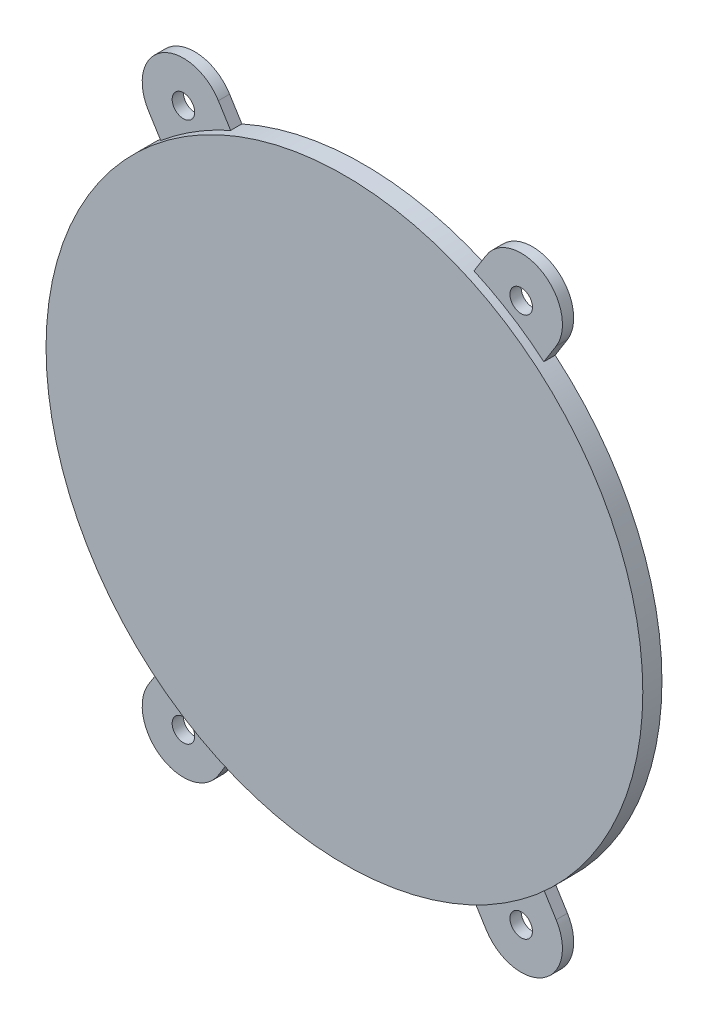
from build123d import *

# Parameters (mm, degrees)
SKETCH_1_R          = 26.5
EXTRUDE_2_DEPTH     = 1.7
EXTRUDE_3_DEPTH     = 1
SKETCH_4_R          = 1
CUT_EXTRUDE_1_DEPTH = 1


with BuildPart() as part:
    # Эскиз1 → Бобышка-Вытянуть2 (new body)
    with BuildSketch(Plane.XY):
        Circle(SKETCH_1_R)
    extrude(amount=EXTRUDE_2_DEPTH)

    # Эскиз3 → Бобышка-Вытянуть3 (add)
    with BuildSketch(Plane.XY):
        with BuildLine():
            Line((0, 6.907283337), (-11.895602995, 25.940248128))
            ThreePointArc((-11.895602995, 25.940248128), (-16.940248128, 27.104397005), (-18.104397005, 22.059751872))
            Line((-18.104397005, 22.059751872), (-4.317052086, 0))
            Line((-4.317052086, 0), (0, 6.907283337))
        make_face()
        with BuildLine():
            Line((11.895602995, 25.940248128), (0, 6.907283337))
            Line((0, 6.907283337), (4.317052086, 0))
            Line((4.317052086, 0), (18.104397005, 22.059751872))
            ThreePointArc((18.104397005, 22.059751872), (16.940248128, 27.104397005), (11.895602995, 25.940248128))
        make_face()
        with BuildLine():
            Line((0, -6.907283337), (-4.317052086, 0))
            Line((-4.317052086, 0), (-18.104397005, -22.059751872))
            ThreePointArc((-18.104397005, -22.059751872), (-16.940248128, -27.104397005), (-11.895602995, -25.940248128))
            Line((-11.895602995, -25.940248128), (0, -6.907283337))
        make_face()
        with BuildLine():
            Line((18.104397005, -22.059751872), (4.317052086, 0))
            Line((4.317052086, 0), (0, -6.907283337))
            Line((0, -6.907283337), (11.895602995, -25.940248128))
            ThreePointArc((11.895602995, -25.940248128), (16.940248128, -27.104397005), (18.104397005, -22.059751872))
        make_face()
    extrude(amount=EXTRUDE_3_DEPTH)

    # Эскиз4 → Вырез-Вытянуть1 (cut)
    with BuildSketch(Plane.XY.offset(1)):
        with Locations((-15, 24)):
            Circle(SKETCH_4_R)
        with Locations((15, 24)):
            Circle(SKETCH_4_R)
        with Locations((15, -24)):
            Circle(SKETCH_4_R)
        with Locations((-15, -24)):
            Circle(SKETCH_4_R)
    extrude(amount=-CUT_EXTRUDE_1_DEPTH, mode=Mode.SUBTRACT)


solid = part.part
